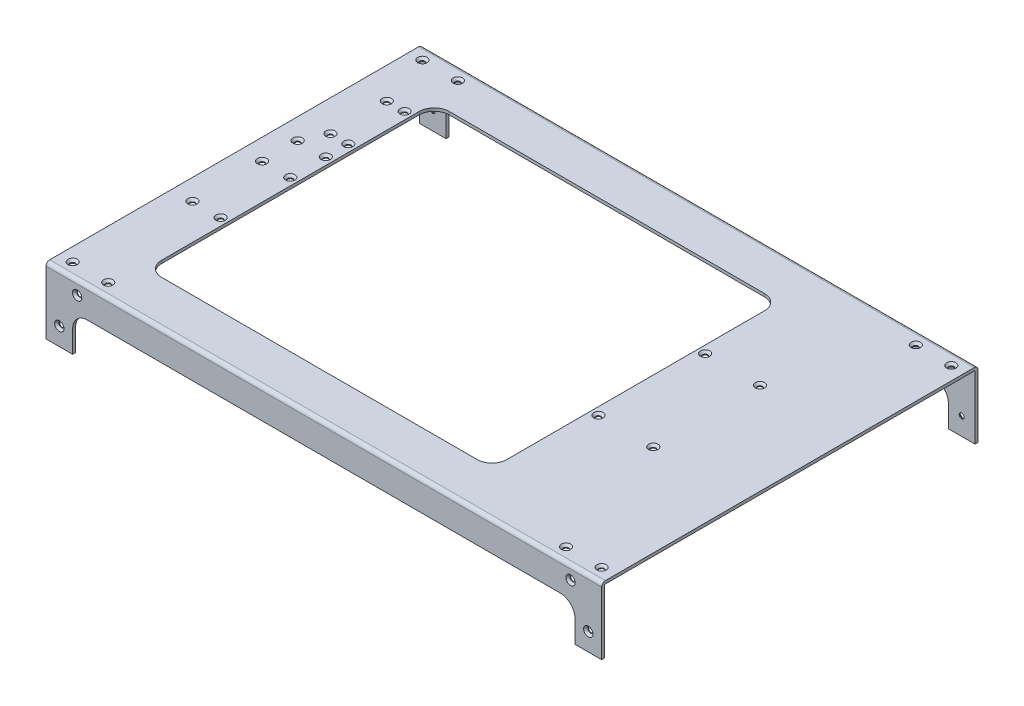
from build123d import *

# Parameters (mm, degrees)
BOSS_EXTRUDE1_DEPTH                             = 187.5
CUT_EXTRUDE1_DEPTH                              = 255
CUT_EXTRUDE2_DEPTH                              = 10
SKETCH4_R                                       = 1.5
CUT_EXTRUDE3_DEPTH                              = 255
SKETCH5_R                                       = 1.5
CUT_EXTRUDE4_DEPTH                              = 10
CSK_FOR_M3_FLAT_HEAD_MACHINE_SCREW1_D           = 3.4
CSK_FOR_M3_FLAT_HEAD_MACHINE_SCREW1_CSINK_D     = 6.3
CSK_FOR_M3_FLAT_HEAD_MACHINE_SCREW1_CSINK_ANGLE = 90
CSK_FOR_M3_FLAT_HEAD_MACHINE_SCREW2_D           = 3.4
CSK_FOR_M3_FLAT_HEAD_MACHINE_SCREW2_DEPTH       = 10
CSK_FOR_M3_FLAT_HEAD_MACHINE_SCREW2_CSINK_D     = 6.3
CSK_FOR_M3_FLAT_HEAD_MACHINE_SCREW2_CSINK_ANGLE = 90
CSK_FOR_M3_FLAT_HEAD_MACHINE_SCREW2_TIP         = 1.021463052
CSK_FOR_M3_FLAT_HEAD_MACHINE_SCREW3_D           = 3.4
CSK_FOR_M3_FLAT_HEAD_MACHINE_SCREW3_DEPTH       = 10
CSK_FOR_M3_FLAT_HEAD_MACHINE_SCREW3_CSINK_D     = 6.3
CSK_FOR_M3_FLAT_HEAD_MACHINE_SCREW3_CSINK_ANGLE = 90
CSK_FOR_M3_FLAT_HEAD_MACHINE_SCREW3_TIP         = 1.021463052


with BuildPart() as part:
    # Sketch1 → Boss-Extrude1 (new body, symmetric)
    with BuildSketch(Plane(origin=(0, 0, 0), x_dir=(0, 0, -1), z_dir=(1, 0, 0))):
        with BuildLine():
            Line((125, -45), (127, -45))
            Line((127, -45), (127, -2.5))
            ThreePointArc((127, -2.5), (126.267766953, -0.732233047), (124.5, 0))
            Line((124.5, 0), (-124.5, 0))
            ThreePointArc((-124.5, 0), (-126.267766953, -0.732233047), (-127, -2.5))
            Line((-127, -2.5), (-127, -45))
            Line((-127, -45), (-125, -45))
            Line((-125, -45), (-125, -2.5))
            ThreePointArc((-125, -2.5), (-124.853553391, -2.146446609), (-124.5, -2))
            Line((-124.5, -2), (124.5, -2))
            ThreePointArc((124.5, -2), (124.853553391, -2.146446609), (125, -2.5))
            Line((125, -2.5), (125, -45))
        make_face()
    extrude(amount=BOSS_EXTRUDE1_DEPTH, both=True)

    # Sketch2 → Cut-Extrude1 (cut, through all)
    with BuildSketch(Plane.XY.offset(127)):
        with BuildLine():
            Line((-169.5, -45), (169.5, -45))
            Line((169.5, -45), (169.5, -30))
            ThreePointArc((169.5, -30), (166.571067812, -22.928932188), (159.5, -20))
            Line((159.5, -20), (-159.5, -20))
            ThreePointArc((-159.5, -20), (-166.571067812, -22.928932188), (-169.5, -30))
            Line((-169.5, -30), (-169.5, -45))
        make_face()
    extrude(amount=-CUT_EXTRUDE1_DEPTH, mode=Mode.SUBTRACT)

    # Sketch3 → Cut-Extrude2 (cut)
    with BuildSketch(Plane(origin=(0, 0, 0), x_dir=(1, 0, 0), z_dir=(0, 1, 0))):
        with BuildLine():
            Line((-139.5, 97), (73.5, 97))
            ThreePointArc((73.5, 97), (80.571067812, 94.071067812), (83.5, 87))
            Line((83.5, 87), (83.5, -87))
            ThreePointArc((83.5, -87), (80.571067812, -94.071067812), (73.5, -97))
            Line((73.5, -97), (-139.5, -97))
            ThreePointArc((-139.5, -97), (-146.571067812, -94.071067812), (-149.5, -87))
            Line((-149.5, -87), (-149.5, 87))
            ThreePointArc((-149.5, 87), (-146.571067812, 94.071067812), (-139.5, 97))
        make_face()
    extrude(amount=-CUT_EXTRUDE2_DEPTH, mode=Mode.SUBTRACT)

    # Sketch4 → Cut-Extrude3 (cut, through all)
    with BuildSketch(Plane.XY.offset(127)):
        with Locations((-178.5, -33)):
            Circle(SKETCH4_R)
        with Locations((-166.5, -9)):
            Circle(SKETCH4_R)
        with Locations((166.5, -9)):
            Circle(SKETCH4_R)
        with Locations((178.5, -33)):
            Circle(SKETCH4_R)
    extrude(amount=-CUT_EXTRUDE3_DEPTH, mode=Mode.SUBTRACT)

    # Sketch5 → Cut-Extrude4 (cut)
    with BuildSketch(Plane(origin=(0, 0, 0), x_dir=(1, 0, 0), z_dir=(0, 1, 0))):
        with Locations(Location((-178.5, 118, 0), (0, 0, 270))):  # turned: the seam where the file's is
            Circle(SKETCH5_R)
        with Locations(Location((-154.5, 118, 0), (0, 0, 270))):  # turned: the seam where the file's is
            Circle(SKETCH5_R)
        with Locations(Location((154.5, 118, 0), (0, 0, 270))):  # turned: the seam where the file's is
            Circle(SKETCH5_R)
        with Locations(Location((178.5, 118, 0), (0, 0, 270))):  # turned: the seam where the file's is
            Circle(SKETCH5_R)
        with Locations(Location((178.5, -118, 0), (0, 0, 270))):  # turned: the seam where the file's is
            Circle(SKETCH5_R)
        with Locations(Location((154.5, -118, 0), (0, 0, 270))):  # turned: the seam where the file's is
            Circle(SKETCH5_R)
        with Locations(Location((-178.5, -118, 0), (0, 0, 270))):  # turned: the seam where the file's is
            Circle(SKETCH5_R)
        with Locations(Location((-154.5, -118, 0), (0, 0, 270))):  # turned: the seam where the file's is
            Circle(SKETCH5_R)
        with Locations(Location((88.5, 41.85, 0), (0, 0, 270))):  # turned: the seam where the file's is
            Circle(SKETCH5_R)
        with Locations(Location((88.5, -30.15, 0), (0, 0, 270))):  # turned: the seam where the file's is
            Circle(SKETCH5_R)
        with Locations(Location((125.5, 41.85, 0), (0, 0, 270))):  # turned: the seam where the file's is
            Circle(SKETCH5_R)
        with Locations(Location((125.5, -30.15, 0), (0, 0, 270))):  # turned: the seam where the file's is
            Circle(SKETCH5_R)
        with Locations(Location((-154.5, 28.85, 0), (0, 0, 270))):  # turned: the seam where the file's is
            Circle(SKETCH5_R)
        with Locations(Location((-173.5, 28.85, 0), (0, 0, 270))):  # turned: the seam where the file's is
            Circle(SKETCH5_R)
        with Locations(Location((-173.5, 4.85, 0), (0, 0, 270))):  # turned: the seam where the file's is
            Circle(SKETCH5_R)
        with Locations(Location((-154.5, 4.85, 0), (0, 0, 270))):  # turned: the seam where the file's is
            Circle(SKETCH5_R)
        with Locations(Location((-154.5, -42.15, 0), (0, 0, 270))):  # turned: the seam where the file's is
            Circle(SKETCH5_R)
        with Locations(Location((-173.5, -42.15, 0), (0, 0, 270))):  # turned: the seam where the file's is
            Circle(SKETCH5_R)
        with Locations(Location((-166.5, 82, 0), (0, 0, 270))):  # turned: the seam where the file's is
            Circle(SKETCH5_R)
        with Locations(Location((-154.5, 82, 0), (0, 0, 270))):  # turned: the seam where the file's is
            Circle(SKETCH5_R)
        with Locations(Location((-166.5, 44, 0), (0, 0, 270))):  # turned: the seam where the file's is
            Circle(SKETCH5_R)
        with Locations(Location((-154.5, 44, 0), (0, 0, 270))):  # turned: the seam where the file's is
            Circle(SKETCH5_R)
    extrude(amount=-CUT_EXTRUDE4_DEPTH, mode=Mode.SUBTRACT)

    # CSK for M3 Flat Head Machine Screw1 (through all)
    with Locations(Plane(origin=(0, 0, 0), x_dir=(-1, 0, 0), z_dir=(0, 1, 0))):
        with Locations((154.5, 118), (178.5, 118), (154.5, 42.15), (173.5, 42.15), (154.5, -4.85), (173.5, -4.85), (173.5, -28.85), (154.5, -28.85), (154.5, -44), (166.5, -44), (166.5, -82), (154.5, -82), (178.5, -118), (154.5, -118), (-154.5, -118), (-178.5, -118), (-125.5, -41.85), (-88.5, -41.85), (-125.5, 30.15), (-88.5, 30.15), (-178.5, 118), (-154.5, 118)):
            CounterSinkHole(CSK_FOR_M3_FLAT_HEAD_MACHINE_SCREW1_D / 2, CSK_FOR_M3_FLAT_HEAD_MACHINE_SCREW1_CSINK_D / 2, counter_sink_angle=CSK_FOR_M3_FLAT_HEAD_MACHINE_SCREW1_CSINK_ANGLE)

    # CSK for M3 Flat Head Machine Screw2
    with Locations(Plane.XY.offset(127)):
        with Locations((166.5, -9), (178.5, -33), (-178.5, -33), (-166.5, -9)):
            CounterSinkHole(CSK_FOR_M3_FLAT_HEAD_MACHINE_SCREW2_D / 2, CSK_FOR_M3_FLAT_HEAD_MACHINE_SCREW2_CSINK_D / 2, depth=CSK_FOR_M3_FLAT_HEAD_MACHINE_SCREW2_DEPTH, counter_sink_angle=CSK_FOR_M3_FLAT_HEAD_MACHINE_SCREW2_CSINK_ANGLE)
            with Locations((0, 0, -(CSK_FOR_M3_FLAT_HEAD_MACHINE_SCREW2_DEPTH + CSK_FOR_M3_FLAT_HEAD_MACHINE_SCREW2_TIP / 2))):  # 118° drill point
                Cone(0, CSK_FOR_M3_FLAT_HEAD_MACHINE_SCREW2_D / 2, CSK_FOR_M3_FLAT_HEAD_MACHINE_SCREW2_TIP, mode=Mode.SUBTRACT)

    # CSK for M3 Flat Head Machine Screw3
    with Locations(Plane(origin=(0, 0, -127), x_dir=(-1, 0, 0), z_dir=(0, 0, -1))):
        with Locations((-166.5, -9), (178.5, -33), (166.5, -9), (-178.5, -33)):
            CounterSinkHole(CSK_FOR_M3_FLAT_HEAD_MACHINE_SCREW3_D / 2, CSK_FOR_M3_FLAT_HEAD_MACHINE_SCREW3_CSINK_D / 2, depth=CSK_FOR_M3_FLAT_HEAD_MACHINE_SCREW3_DEPTH, counter_sink_angle=CSK_FOR_M3_FLAT_HEAD_MACHINE_SCREW3_CSINK_ANGLE)
            with Locations((0, 0, -(CSK_FOR_M3_FLAT_HEAD_MACHINE_SCREW3_DEPTH + CSK_FOR_M3_FLAT_HEAD_MACHINE_SCREW3_TIP / 2))):  # 118° drill point
                Cone(0, CSK_FOR_M3_FLAT_HEAD_MACHINE_SCREW3_D / 2, CSK_FOR_M3_FLAT_HEAD_MACHINE_SCREW3_TIP, mode=Mode.SUBTRACT)


solid = part.part
